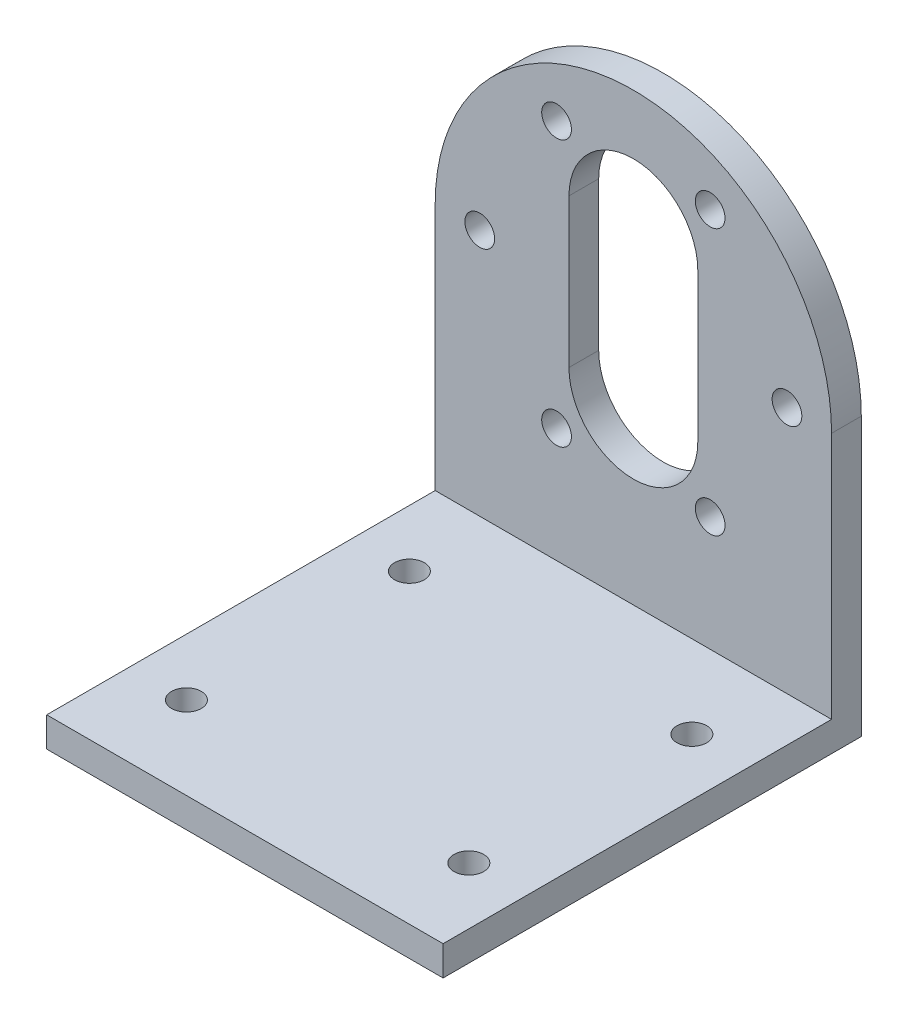
from build123d import *

# Parameters (mm, degrees)
ESBO_O1_R                = 1.5
RESSALTO_EXTRUS_O1_DEPTH = 3
ESBO_O2_W                = 40
ESBO_O2_H                = 42.2
ESBO_O2_R                = 1.5
RESSALTO_EXTRUS_O2_DEPTH = 3


with BuildPart() as part:
    # Esboço1 → Ressalto-extrusão1 (new body)
    with BuildSketch(Plane.XY):
        with BuildLine():
            Line((-20, 0), (-20, -28))
            Line((-20, -28), (20, -28))
            Line((20, -28), (20, 0))
            ThreePointArc((20, 0), (0, 20), (-20, 0))
        make_face()
        with Locations((-15.5, 0)):
            Circle(ESBO_O1_R, mode=Mode.SUBTRACT)
        with Locations((-7.75, 13.423393759)):
            Circle(ESBO_O1_R, mode=Mode.SUBTRACT)
        with Locations((7.75, 13.423393759)):
            Circle(ESBO_O1_R, mode=Mode.SUBTRACT)
        with Locations((15.5, 0)):
            Circle(ESBO_O1_R, mode=Mode.SUBTRACT)
        with Locations((7.75, -13.423393759)):
            Circle(ESBO_O1_R, mode=Mode.SUBTRACT)
        with Locations((-7.75, -13.423393759)):
            Circle(ESBO_O1_R, mode=Mode.SUBTRACT)
        with BuildLine():
            Line((6.5, 7.5), (6.5, -7.5))
            ThreePointArc((6.5, -7.5), (0, -14), (-6.5, -7.5))
            Line((-6.5, -7.5), (-6.5, 7.5))
            ThreePointArc((-6.5, 7.5), (0, 14), (6.5, 7.5))
        make_face(mode=Mode.SUBTRACT)
    extrude(amount=RESSALTO_EXTRUS_O1_DEPTH)

    # Esboço2 → Ressalto-extrusão2 (add)
    with BuildSketch(Plane.XZ.offset(28)):
        with Locations((0, 21.1)):
            Rectangle(ESBO_O2_W, ESBO_O2_H)
        with Locations((-14.25, 11.35)):
            Circle(ESBO_O2_R, mode=Mode.SUBTRACT)
        with Locations((14.25, 11.35)):
            Circle(ESBO_O2_R, mode=Mode.SUBTRACT)
        with Locations((14.25, 33.85)):
            Circle(ESBO_O2_R, mode=Mode.SUBTRACT)
        with Locations((-14.25, 33.85)):
            Circle(ESBO_O2_R, mode=Mode.SUBTRACT)
    extrude(amount=-RESSALTO_EXTRUS_O2_DEPTH)


solid = part.part
